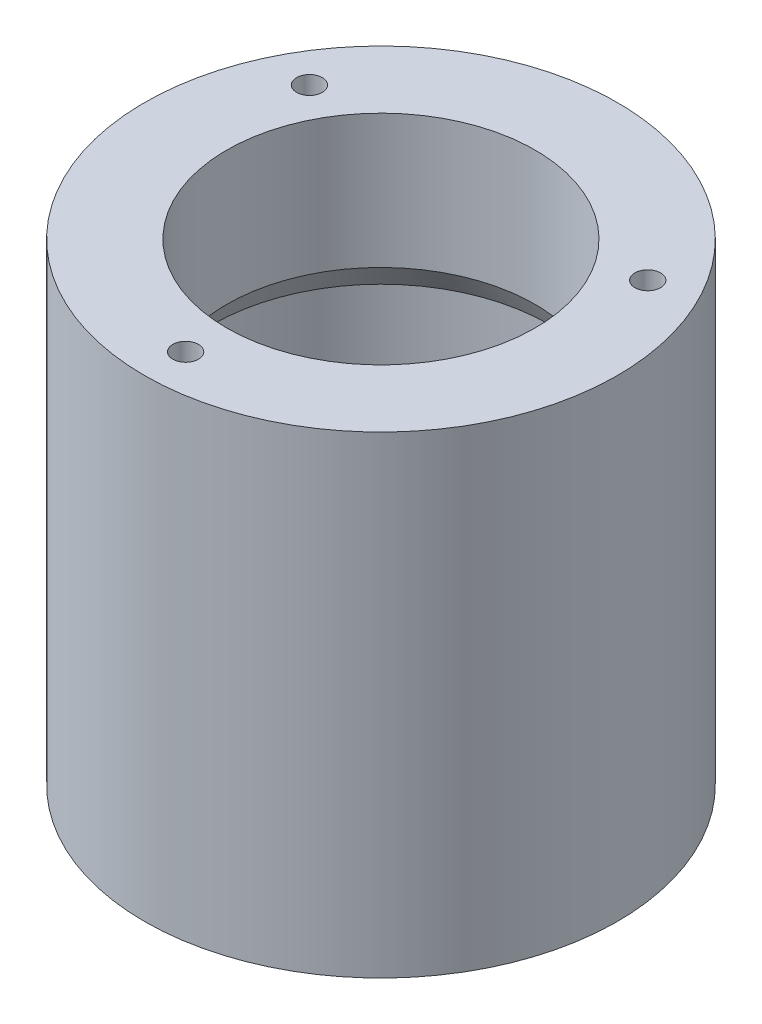
from build123d import *

# Parameters (mm, degrees)
ESQUISSE2_R                  = 12.5
ENL_V_MAT_EXTRU_1_DEPTH      = 47
R_P_TITION_CIRCULAIRE1_COUNT = 3
R_P_TITION_CIRCULAIRE2_COUNT = 3


with BuildPart() as part:
    # Esquisse1 → Révolution1 (revolve)
    with BuildSketch(Plane.XY, mode=Mode.PRIVATE) as r_volution1_sk:
        Polygon((0, 0), (23, 0), (23, 46), (15, 46), (15, 33), (16.37708167, 30.614824582), (16.37708167, 18.385175418), (15, 16), (15, 6), (0, 6), align=None)
    revolve(r_volution1_sk.sketch.rotate(Axis((0, 6, 0), (0, -1, 0)), 90), axis=Axis((0, 6, 0), (0, -1, 0)))  # turned: the seam where the file's is

    # Esquisse2 → Enlèv. mat.-Extru.1 (cut, through all)
    with BuildSketch(Plane.XZ):
        with Locations(Location((0, 0, 0), (0, 0, 270))):  # turned: the seam where the file's is
            Circle(ESQUISSE2_R)
    extrude(amount=-ENL_V_MAT_EXTRU_1_DEPTH, mode=Mode.SUBTRACT)

    # Esquisse3 → Trou taraudé M51 (revolve, cut)
    with BuildSketch(Plane(origin=(0, 0, 19), x_dir=(0, 0, -1), z_dir=(1, 0, 0))):
        Polygon((0, 0), (0, 13.2618073), (2.1, 12), (2.1, 0), align=None)
    trou_taraud_m51 = revolve(axis=Axis((0, -6.35, 19), (0, 1, 0)), mode=Mode.SUBTRACT)

    # Répétition circulaire1: Trou taraudé M51 ×3 about axis
    r_p_tition_circulaire1_axis = Axis((0, 0, 0), (0, 1, 0))
    for i in range(1, R_P_TITION_CIRCULAIRE1_COUNT):
        add(trou_taraud_m51.rotate(r_p_tition_circulaire1_axis, i * 360 / R_P_TITION_CIRCULAIRE1_COUNT), mode=Mode.SUBTRACT)

    # Esquisse7 → Trou taraudé M31 (revolve, cut)
    with BuildSketch(Plane(origin=(0, 46, 19), x_dir=(0, 0, 1), z_dir=(1, 0, 0))):
        Polygon((0, 0), (0, 9.251075774), (1.25, 8.5), (1.25, 0), align=None)
    trou_taraud_m31 = revolve(axis=Axis((0, 52.35, 19), (0, -1, 0)), mode=Mode.SUBTRACT)

    # Répétition circulaire2: Trou taraudé M31 ×3 about axis
    r_p_tition_circulaire2_axis = Axis((0, 0, 0), (0, 1, 0))
    for i in range(1, R_P_TITION_CIRCULAIRE2_COUNT):
        add(trou_taraud_m31.rotate(r_p_tition_circulaire2_axis, i * 360 / R_P_TITION_CIRCULAIRE2_COUNT), mode=Mode.SUBTRACT)


solid = part.part
